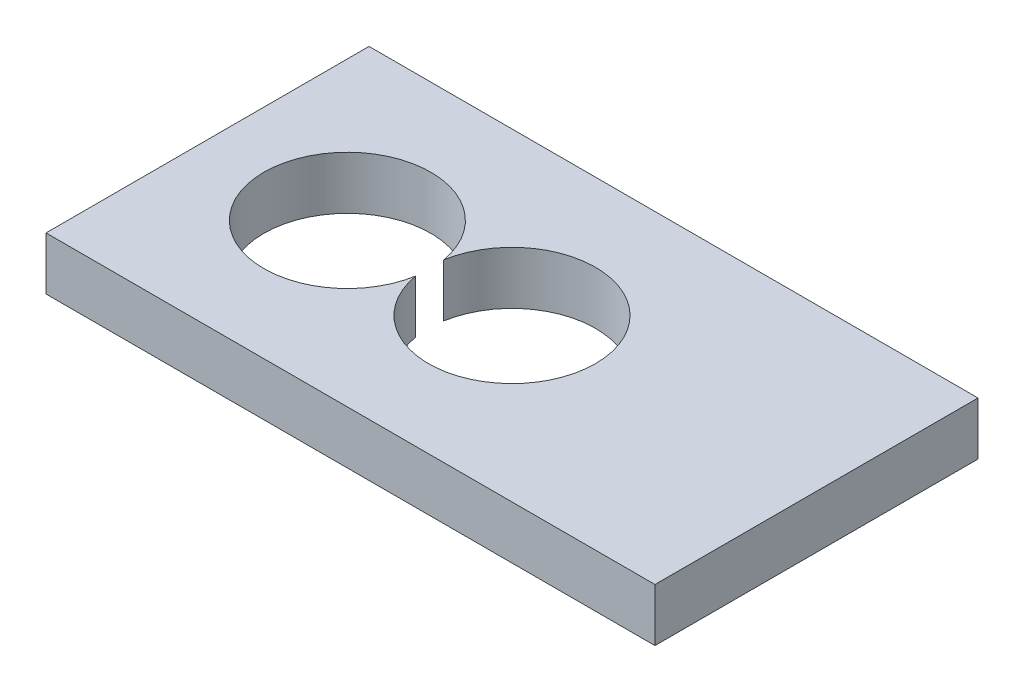
from build123d import *

# Parameters (mm, degrees)
SKETCH1_W           = 51.785459028
SKETCH1_H           = 27.470306908
BOSS_EXTRUDE1_DEPTH = 4.5


with BuildPart() as part:
    # Sketch1 → Boss-Extrude1 (new body)
    with BuildSketch(Plane(origin=(0, 0, 0), x_dir=(1, 0, 0), z_dir=(0, 1, 0))):
        Rectangle(SKETCH1_W, SKETCH1_H)
        with BuildLine():
            ThreePointArc((-7, 1.187434209), (-21.1, 0), (-7, -1.187434209))
            ThreePointArc((-7, -1.187434209), (7.1, 0), (-7, 1.187434209))
        make_face(mode=Mode.SUBTRACT)
    extrude(amount=-BOSS_EXTRUDE1_DEPTH)


solid = part.part
